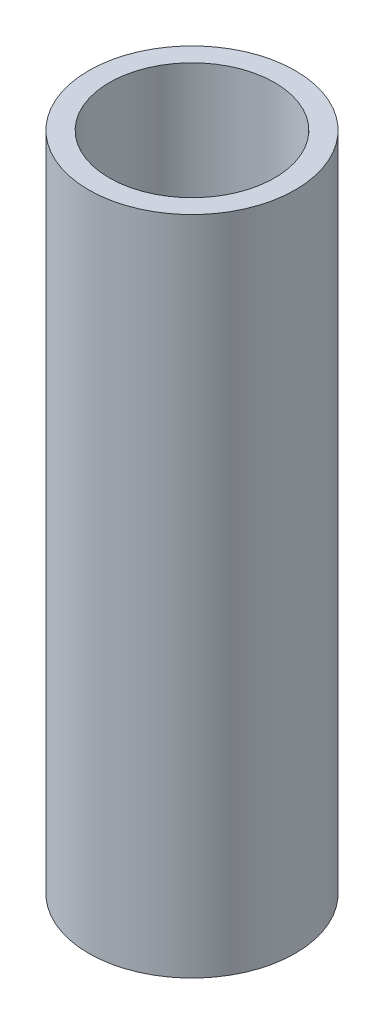
from build123d import *

# Parameters (mm, degrees)
SKETCH1_R           = 2.5
SKETCH1_R_2         = 2
BOSS_EXTRUDE1_DEPTH = 16


with BuildPart() as part:
    # Sketch1 → Boss-Extrude1 (new body)
    with BuildSketch(Plane(origin=(0, 0, 0), x_dir=(1, 0, 0), z_dir=(0, 1, 0))):
        Circle(SKETCH1_R)
        Circle(SKETCH1_R_2, mode=Mode.SUBTRACT)
    extrude(amount=BOSS_EXTRUDE1_DEPTH)


solid = part.part
